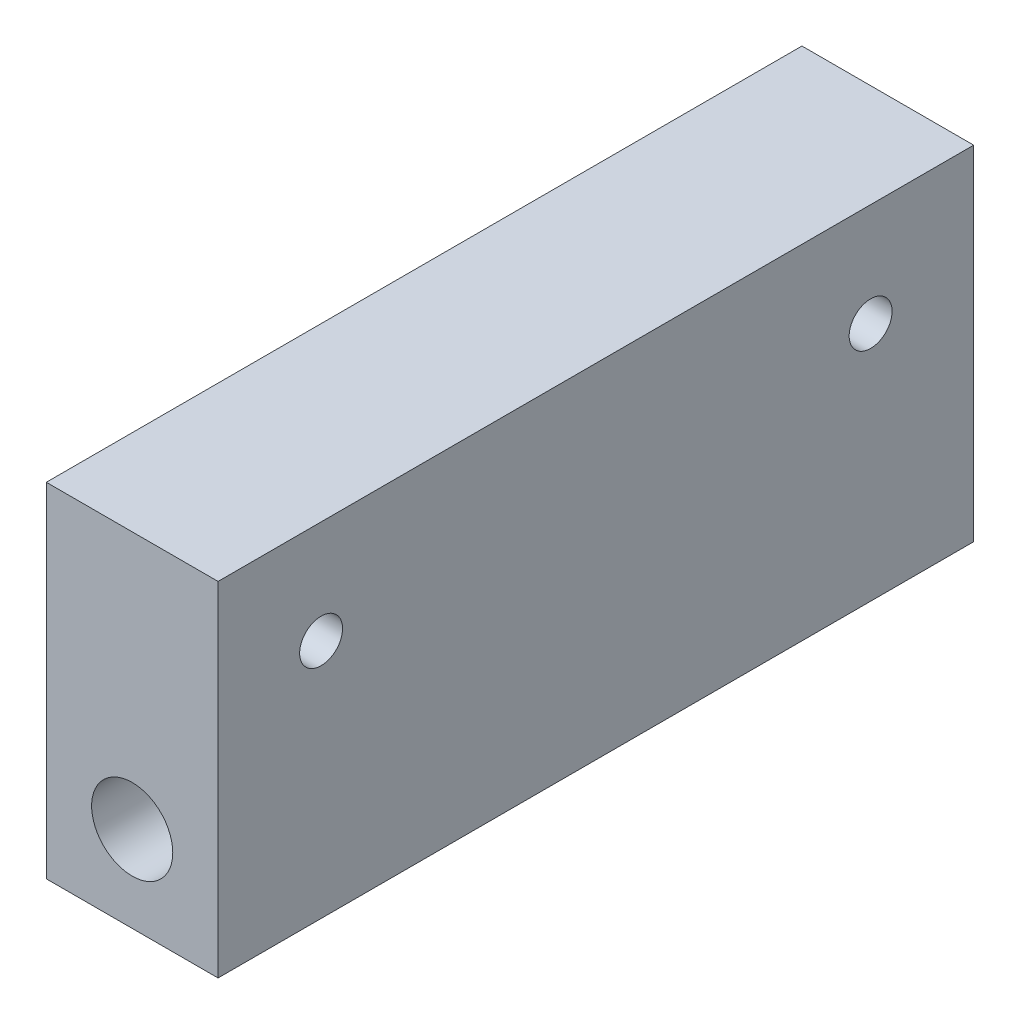
from build123d import *

# Parameters (mm, degrees)
SKETCH1_W           = 31.75
SKETCH1_H           = 63.5
SKETCH1_R           = 7.5
BOSS_EXTRUDE1_DEPTH = 139.7
SKETCH2_R           = 3.96875
CUT_EXTRUDE1_DEPTH  = 139.7


with BuildPart() as part:
    # Sketch1 → Boss-Extrude1 (new body)
    with BuildSketch(Plane.XY):
        with Locations((15.875, 31.75)):
            Rectangle(SKETCH1_W, SKETCH1_H)
        with Locations((15.875, 15.875)):
            Circle(SKETCH1_R, mode=Mode.SUBTRACT)
    extrude(amount=-BOSS_EXTRUDE1_DEPTH)

    # Sketch2 → Cut-Extrude1 (cut)
    with BuildSketch(Plane(origin=(31.75, 0, 0), x_dir=(0, 0, -1), z_dir=(1, 0, 0))):
        with Locations((19.05, 44.45)):
            Circle(SKETCH2_R)
        with Locations((120.65, 44.45)):
            Circle(SKETCH2_R)
    extrude(amount=-CUT_EXTRUDE1_DEPTH, mode=Mode.SUBTRACT)


solid = part.part
